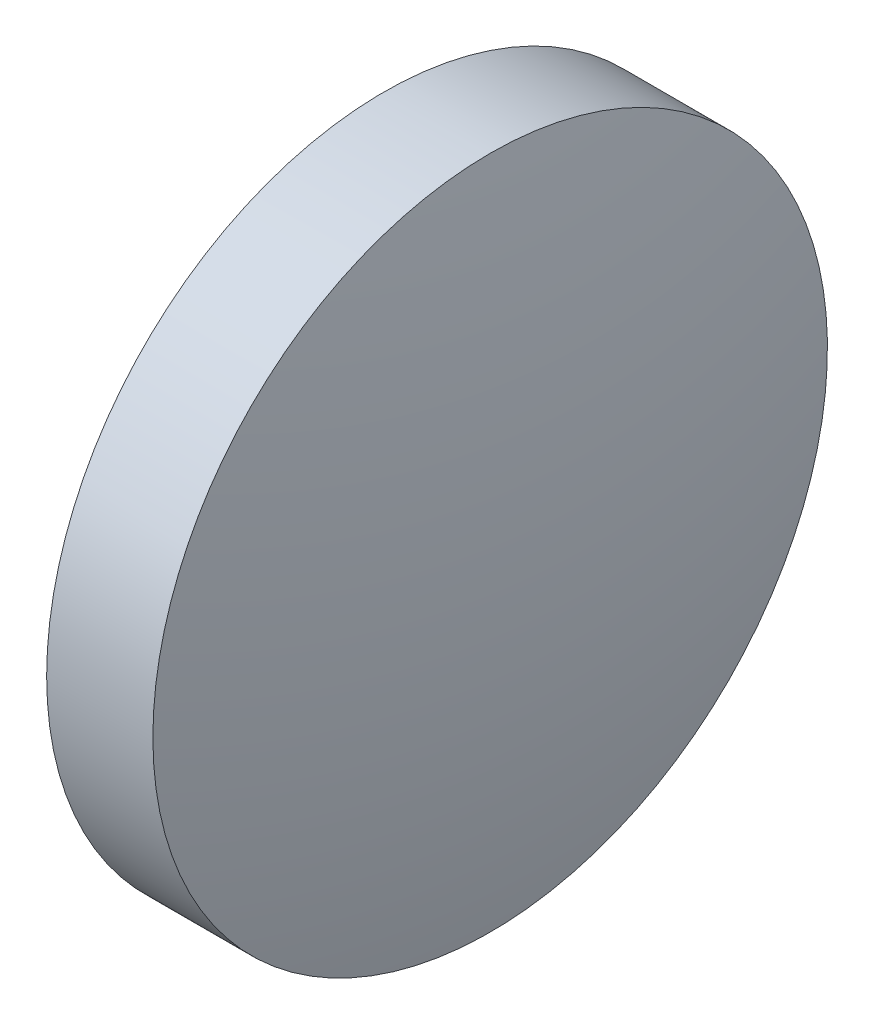
from build123d import *


with BuildPart() as part:
    # 草图1 → 旋转1 (revolve)
    with BuildSketch(Plane.XY):
        with BuildLine():
            Line((458.394914726, 88.534233583), (458.394914726, 94.884233583))
            Line((458.394914726, 94.884233583), (460.394914726, 94.884233583))
            ThreePointArc((460.394914726, 94.884233583), (460.919386281, 91.728466668), (461.094914726, 88.534233583))
            Line((461.094914726, 88.534233583), (458.394914726, 88.534233583))
        make_face()
    revolve(axis=Axis((456.13438358, 88.534233583, 0), (1, 0, 0)))


solid = part.part
